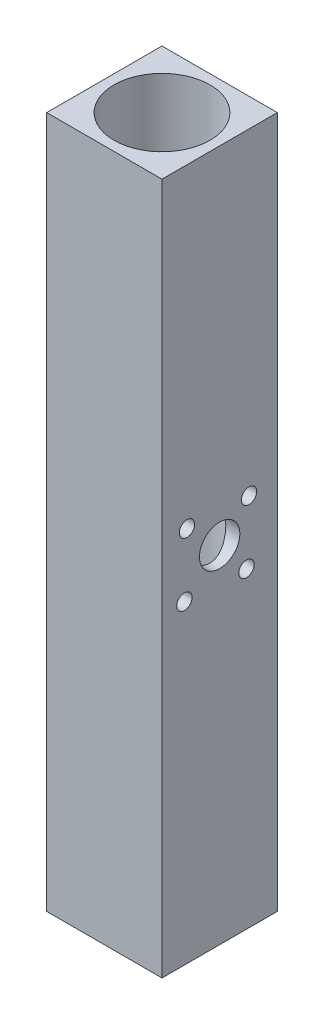
from build123d import *

# Parameters (mm, degrees)
SKETCH1_W           = 76.2
SKETCH1_H           = 76.2
SKETCH1_R           = 31.75
BOSS_EXTRUDE1_DEPTH = 457.2
SKETCH2_R           = 13.335
CUT_EXTRUDE1_DEPTH  = 914.4
SKETCH3_R           = 5.08
CUT_EXTRUDE2_DEPTH  = 914.4


with BuildPart() as part:
    # Sketch1 → Boss-Extrude1 (new body)
    with BuildSketch(Plane(origin=(0, 0, 0), x_dir=(1, 0, 0), z_dir=(0, 1, 0))):
        with Locations((38.1, 38.1)):
            Rectangle(SKETCH1_W, SKETCH1_H)
        with Locations((38.1, 38.1)):
            Circle(SKETCH1_R, mode=Mode.SUBTRACT)
    extrude(amount=BOSS_EXTRUDE1_DEPTH)

    # Sketch2 → Cut-Extrude1 (cut)
    with BuildSketch(Plane.ZY):
        with Locations((-38.1, 228.6)):
            Circle(SKETCH2_R)
    extrude(amount=-CUT_EXTRUDE1_DEPTH, mode=Mode.SUBTRACT)

    # Sketch3 → Cut-Extrude2 (cut)
    with BuildSketch(Plane.ZY):
        with Locations((-57.515901481, 247.247263344)):
            Circle(SKETCH3_R)
        with Locations((-16.522072817, 248.95626833)):
            Circle(SKETCH3_R)
        with Locations((-14.81306783, 207.962439666)):
            Circle(SKETCH3_R)
        with Locations((-55.806896495, 206.253434679)):
            Circle(SKETCH3_R)
    extrude(amount=-CUT_EXTRUDE2_DEPTH, mode=Mode.SUBTRACT)


solid = part.part
